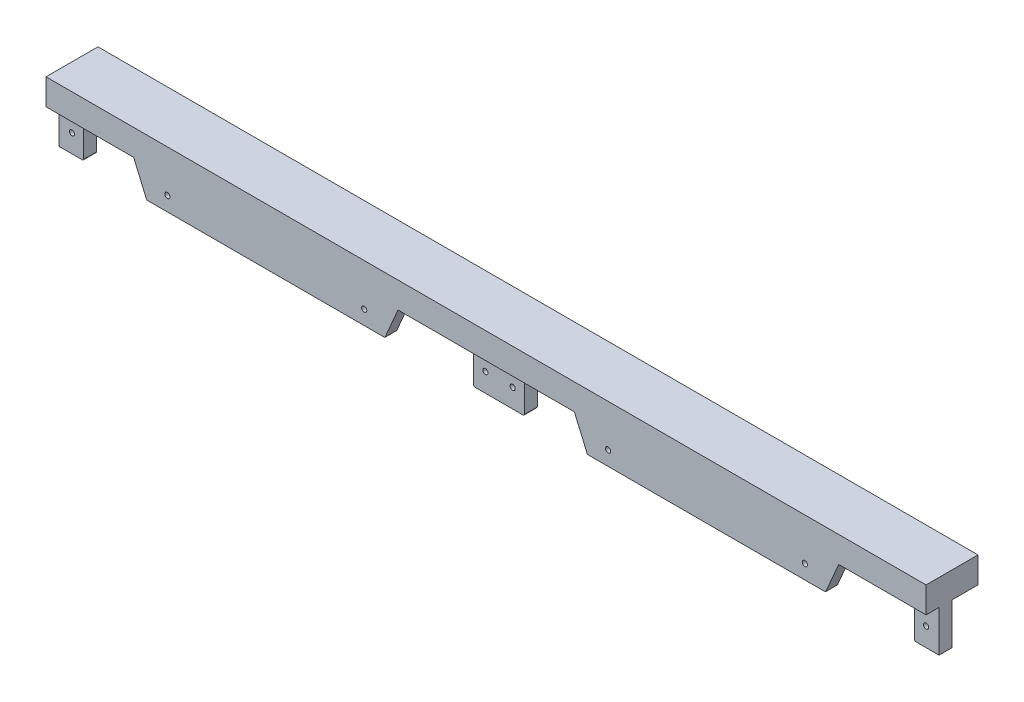
from build123d import *

# Parameters (mm, degrees)
BOSS_EXTRUDE6_DEPTH     = 2.25
BOSS_EXTRUDE6_2_DEPTH   = 2.25
BOSS_EXTRUDE7_DEPTH     = 10
BOSS_EXTRUDE8_START     = -2.5
BOSS_EXTRUDE8_DEPTH     = 2.5
CUT_EXTRUDE1_DEPTH      = 133.327777388
CUT_EXTRUDE1_DEPTH_BACK = 133.327777388
SKETCH8_R               = 0.5


with BuildPart() as part:
    # Sketch7 → Boss-Extrude6 (new body)
    with BuildSketch(Plane.XY):
        with BuildLine():
            Line((26.052322057, 10.550664975), (28.537398615, 16.333832112))
            Line((28.537398615, 16.333832112), (-22.352574149, 16.333832112))
            Line((-22.352574149, 16.333832112), (-19.910011337, 10.634068342))
            ThreePointArc((-19.910011337, 10.634068342), (-19.816511792, 10.522258081), (-19.67689491, 10.480415214))
            Line((-19.67689491, 10.480415214), (25.816632323, 10.480415214))
            ThreePointArc((25.816632323, 10.480415214), (25.943590008, 10.484966358), (26.052322057, 10.550664975))
        make_face()
    extrude(amount=-BOSS_EXTRUDE6_DEPTH)



with BuildPart() as body_2:
    # Sketch7 → Boss-Extrude6 2 (new body)
    with BuildSketch(Plane.XY):
        with BuildLine():
            Line((113.387398615, 16.333832112), (62.497425851, 16.333832112))
            Line((62.497425851, 16.333832112), (64.939988663, 10.634068342))
            ThreePointArc((64.939988663, 10.634068342), (65.033488208, 10.522258081), (65.17310509, 10.480415214))
            Line((65.17310509, 10.480415214), (110.666632323, 10.480415214))
            ThreePointArc((110.666632323, 10.480415214), (110.793590008, 10.484966358), (110.902322057, 10.550664975))
            Line((110.902322057, 10.550664975), (113.387398615, 16.333832112))
        make_face()
    extrude(amount=-BOSS_EXTRUDE6_2_DEPTH)


with BuildPart() as part_1:
    add(part.part)

    add(body_2.part)  # Boss-Extrude7 merges body 2
    # Sketch7_12 → Boss-Extrude7 (add)
    with BuildSketch(Plane.XY):
        Polygon((-22.352574149, 16.333832112), (28.537398615, 16.333832112), (40.61156201, 16.333832112), (50.366516028, 16.333832112), (62.497425851, 16.333832112), (113.387398615, 16.333832112), (125.46156201, 16.333832112), (130.21331835, 16.333832112), (130.21331835, 21.333832112), (-39.23668165, 21.333832112), (-39.23668165, 16.333832112), (-34.483483972, 16.333832112), align=None)
    extrude(amount=-BOSS_EXTRUDE7_DEPTH)

    # Sketch7_13 → Boss-Extrude8 (add)
    with BuildSketch(Plane.XY.offset(BOSS_EXTRUDE8_START)):
        with BuildLine():
            Line((50.366516028, 16.333832112), (40.61156201, 16.333832112))
            Line((40.61156201, 16.333832112), (40.61156201, 8.615866414))
            ThreePointArc((40.61156201, 8.615866414), (40.685812272, 8.43656527), (40.86508696, 8.362251153))
            Line((40.86508696, 8.362251153), (50.113000159, 8.362251153))
            ThreePointArc((50.113000159, 8.362251153), (50.292268976, 8.436568478), (50.366516028, 8.61586641))
            Line((50.366516028, 8.61586641), (50.366516028, 16.333832112))
        make_face()
        with BuildLine():
            Line((-34.483483972, 8.733645436), (-34.483483972, 16.333832112))
            Line((-34.483483972, 16.333832112), (-39.23668165, 16.333832112))
            Line((-39.23668165, 16.333832112), (-39.23668165, 8.480030179))
            Line((-39.23668165, 8.480030179), (-34.736999841, 8.480030179))
            ThreePointArc((-34.736999841, 8.480030179), (-34.557731024, 8.554347504), (-34.483483972, 8.733645436))
        make_face()
        with BuildLine():
            Line((130.21331835, 16.333832112), (125.46156201, 16.333832112))
            Line((125.46156201, 16.333832112), (125.46156201, 8.615866414))
            ThreePointArc((125.46156201, 8.615866414), (125.535812272, 8.43656527), (125.71508696, 8.362251153))
            Line((125.71508696, 8.362251153), (130.21331835, 8.362251153))
            Line((130.21331835, 8.362251153), (130.21331835, 16.333832112))
        make_face()
    extrude(amount=-BOSS_EXTRUDE8_DEPTH)

    # Sketch8 → Cut-Extrude1 (cut, two sides: drawn at the far end of the back side and taken through both)
    with BuildSketch(Plane.XY.offset(-CUT_EXTRUDE1_DEPTH_BACK)):
        with Locations((-36.73668165, 11.983669629)):
            Circle(SKETCH8_R)
        with Locations((-15.856255457, 13.233669629)):
            Circle(SKETCH8_R)
        with Locations((22.035256017, 13.233669629)):
            Circle(SKETCH8_R)
        with Locations((42.86331835, 11.983669629)):
            Circle(SKETCH8_R)
        with Locations((48.11331835, 11.983669629)):
            Circle(SKETCH8_R)
        with Locations((68.993744543, 13.233669629)):
            Circle(SKETCH8_R)
        with Locations((106.885256017, 13.233669629)):
            Circle(SKETCH8_R)
        with Locations((127.71331835, 11.983669629)):
            Circle(SKETCH8_R)
    extrude(amount=CUT_EXTRUDE1_DEPTH + CUT_EXTRUDE1_DEPTH_BACK, mode=Mode.SUBTRACT)


solid = part_1.part
